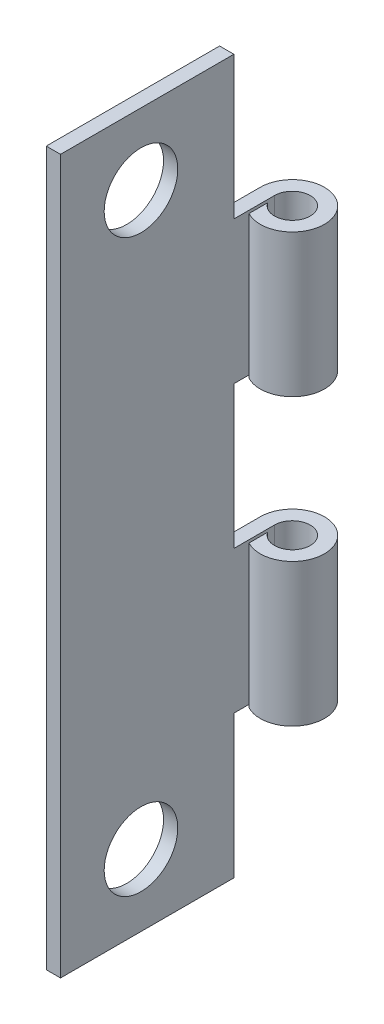
from build123d import *

# Parameters (mm, degrees)
BOSS_EXTRUDE2_DEPTH = 31.75
SKETCH8_W           = 3.6195
SKETCH8_H           = 6.35
CUT_EXTRUDE3_DEPTH  = 3.8575
SKETCH15_R          = 1.6383
CUT_EXTRUDE5_DEPTH  = 3.8575


with BuildPart() as part:
    # Sketch4 → Boss-Extrude2 (new body)
    with BuildSketch(Plane(origin=(0, 0, 0), x_dir=(1, 0, 0), z_dir=(0, 1, 0))):
        with BuildLine():
            Line((0, 0), (0, -9.525))
            Line((0, -9.525), (0.635, -9.525))
            Line((0.635, -9.525), (0.635, 0))
            ThreePointArc((0.635, 0), (2.190088254, 0.224506403), (0.762, -0.430677954))
            Line((0.762, -0.430677954), (0.762, -1.263634045))
            ThreePointArc((0.762, -1.263634045), (2.652258403, 0.737803327), (0, 0))
        make_face()
    extrude(amount=BOSS_EXTRUDE2_DEPTH)

    # Sketch8 → Cut-Extrude3 (cut, through all)
    with BuildSketch(Plane(origin=(0, 0, 0), x_dir=(0, 0, -1), z_dir=(1, 0, 0))):
        with Locations((0, 3.175)):
            Rectangle(SKETCH8_W, SKETCH8_H)
        with Locations((0, 15.875)):
            Rectangle(SKETCH8_W, SKETCH8_H)
        with Locations((0, 28.575)):
            Rectangle(SKETCH8_W, SKETCH8_H)
    extrude(amount=CUT_EXTRUDE3_DEPTH, mode=Mode.SUBTRACT)

    # Sketch15 → Cut-Extrude5 (cut, through all)
    with BuildSketch(Plane(origin=(0, 0, 0), x_dir=(0, 0, -1), z_dir=(1, 0, 0))):
        with Locations((-5.9436, 3.175)):
            Circle(SKETCH15_R)
    cut_extrude5 = extrude(amount=CUT_EXTRUDE5_DEPTH, mode=Mode.SUBTRACT)

    # Mirror1: Cut-Extrude5 across plane
    add(cut_extrude5.mirror(Plane(origin=(0, 15.875, 0), x_dir=(0, 0, 1), z_dir=(0, -1, 0))), mode=Mode.SUBTRACT)


solid = part.part
